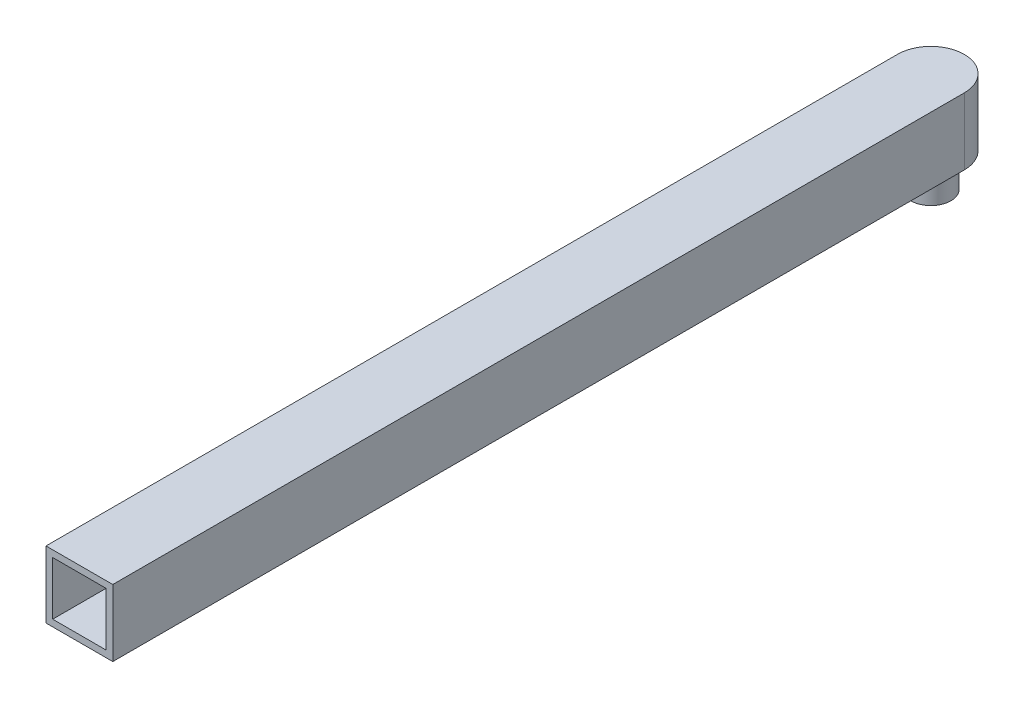
from build123d import *

# Parameters (mm, degrees)
BOSS_EXTRUDE1_DEPTH = 25.4
SKETCH2_W           = 20.32
SKETCH2_H           = 20.32
CUT_EXTRUDE1_DEPTH  = 322.58
SKETCH3_R           = 7.62
BOSS_EXTRUDE2_DEPTH = 12.7


with BuildPart() as part:
    # Sketch1 → Boss-Extrude1 (new body)
    with BuildSketch(Plane(origin=(0, 0, 0), x_dir=(1, 0, 0), z_dir=(0, 1, 0))):
        with BuildLine():
            Line((-12.7, -161.925), (12.7, -161.925))
            Line((12.7, -161.925), (12.7, 161.925))
            ThreePointArc((12.7, 161.925), (0, 174.625), (-12.7, 161.925))
            Line((-12.7, 161.925), (-12.7, -161.925))
        make_face()
    extrude(amount=BOSS_EXTRUDE1_DEPTH)

    # Sketch2 → Cut-Extrude1 (cut)
    with BuildSketch(Plane.XY.offset(161.925)):
        with Locations((0, 12.7)):
            Rectangle(SKETCH2_W, SKETCH2_H)
    extrude(amount=-CUT_EXTRUDE1_DEPTH, mode=Mode.SUBTRACT)

    # Sketch3 → Boss-Extrude2 (add)
    with BuildSketch(Plane.XZ):
        with Locations((0, -161.925)):
            Circle(SKETCH3_R)
    extrude(amount=BOSS_EXTRUDE2_DEPTH)


solid = part.part
